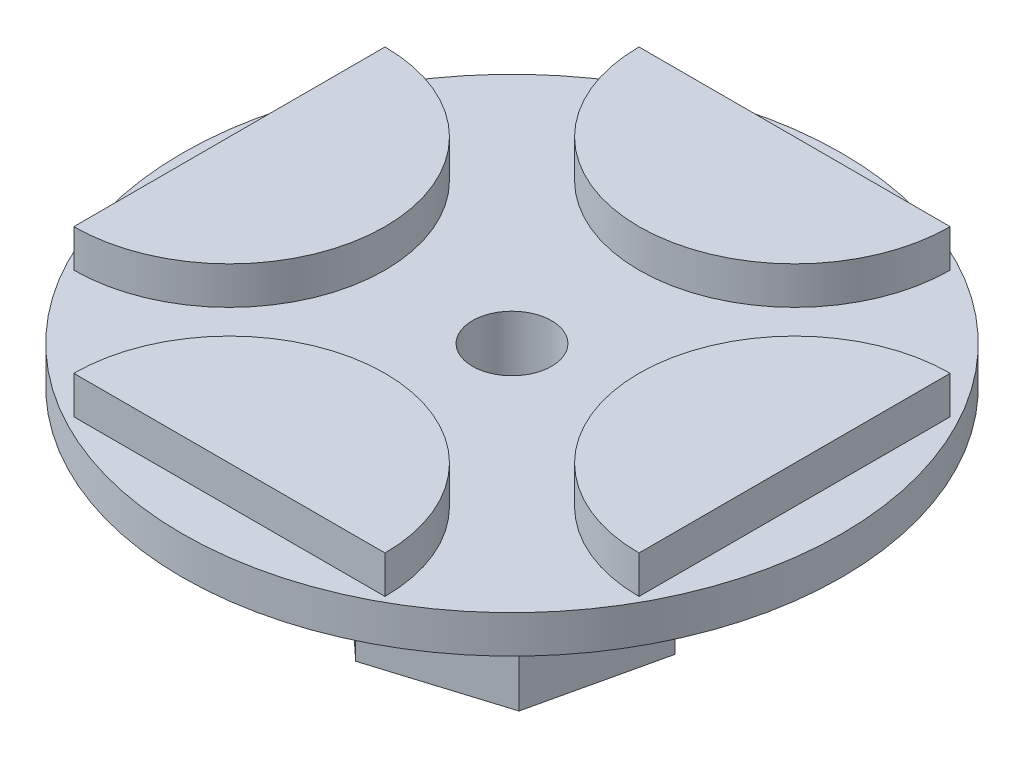
from build123d import *

# Parameters (mm, degrees)
SKETCH4_R               = 17.5
BOSS_EXTRUDE1_DEPTH     = 2
BOSS_EXTRUDE2_DEPTH     = 4
BOSS_EXTRUDE3_DEPTH     = 10
SKETCH6_R               = 2.1
CUT_EXTRUDE1_DEPTH      = 3
CUT_EXTRUDE1_DEPTH_BACK = 13


with BuildPart() as part:
    # Sketch4 → Boss-Extrude1 (new body)
    with BuildSketch(Plane(origin=(0, 0, 0), x_dir=(1, 0, 0), z_dir=(0, 1, 0))):
        Circle(SKETCH4_R)
    extrude(amount=BOSS_EXTRUDE1_DEPTH)

    # Sketch1 → Boss-Extrude2 (add)
    with BuildSketch(Plane(origin=(0, 0, 0), x_dir=(1, 0, 0), z_dir=(0, 1, 0))):
        with BuildLine():
            Line((-8.26, 15), (8.26, 15))
            ThreePointArc((8.26, 15), (0, 6.74), (-8.26, 15))
        make_face()
        with BuildLine():
            Line((15, 8.26), (15, -8.26))
            ThreePointArc((15, -8.26), (6.74, 0), (15, 8.26))
        make_face()
        with BuildLine():
            Line((8.26, -15), (-8.26, -15))
            ThreePointArc((-8.26, -15), (0, -6.74), (8.26, -15))
        make_face()
        with BuildLine():
            Line((-15, -8.26), (-15, 8.26))
            ThreePointArc((-15, 8.26), (-6.74, 0), (-15, -8.26))
        make_face()
    extrude(amount=BOSS_EXTRUDE2_DEPTH)

    # Sketch5 → Boss-Extrude3 (add)
    with BuildSketch(Plane.XZ):
        Polygon((-6.619767116, 2.044182802), (-5.080197795, -4.710795089), (1.539569322, -6.754977891), (6.619767116, -2.044182802), (5.080197795, 4.710795089), (-1.539569322, 6.754977891), align=None)
    extrude(amount=BOSS_EXTRUDE3_DEPTH)

    # Sketch6 → Cut-Extrude1 (cut, two sides)
    with BuildSketch(Plane(origin=(0, 2, 0), x_dir=(1, 0, 0), z_dir=(0, 1, 0))) as cut_extrude1_sk:
        Circle(SKETCH6_R)
    extrude(amount=CUT_EXTRUDE1_DEPTH, mode=Mode.SUBTRACT)
    extrude(cut_extrude1_sk.sketch, amount=-CUT_EXTRUDE1_DEPTH_BACK, mode=Mode.SUBTRACT)


solid = part.part
